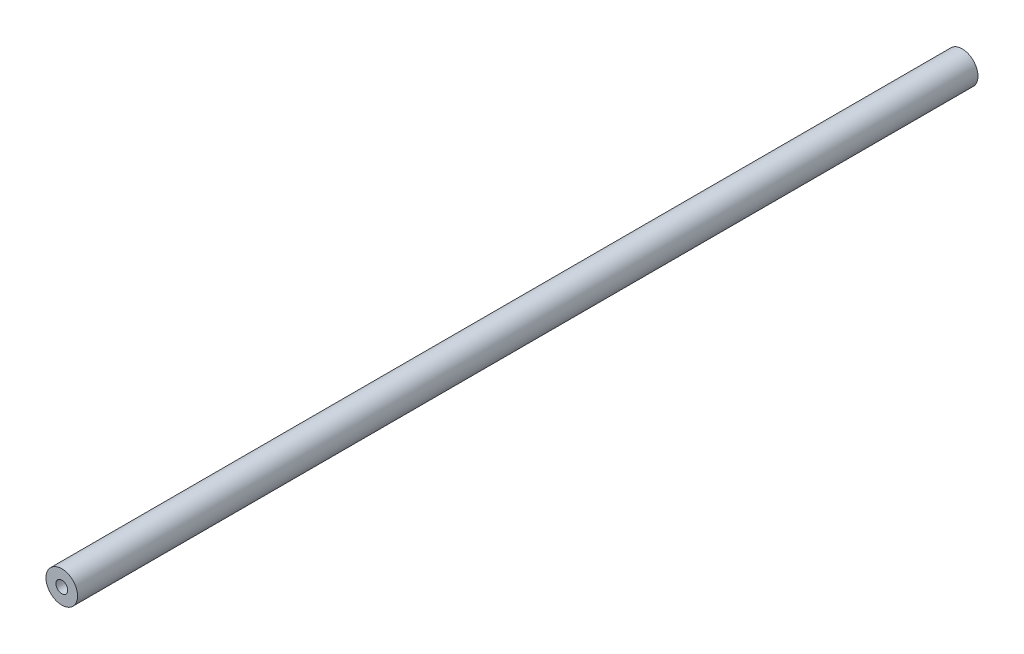
from build123d import *

# Parameters (mm, degrees)
SKETCH1_R           = 12.7
SKETCH1_R_2         = 4.7625
BOSS_EXTRUDE1_DEPTH = 723.9


with BuildPart() as part:
    # Sketch1 → Boss-Extrude1 (new body)
    with BuildSketch(Plane.XY):
        Circle(SKETCH1_R)
        Circle(SKETCH1_R_2, mode=Mode.SUBTRACT)
    extrude(amount=BOSS_EXTRUDE1_DEPTH)


solid = part.part
